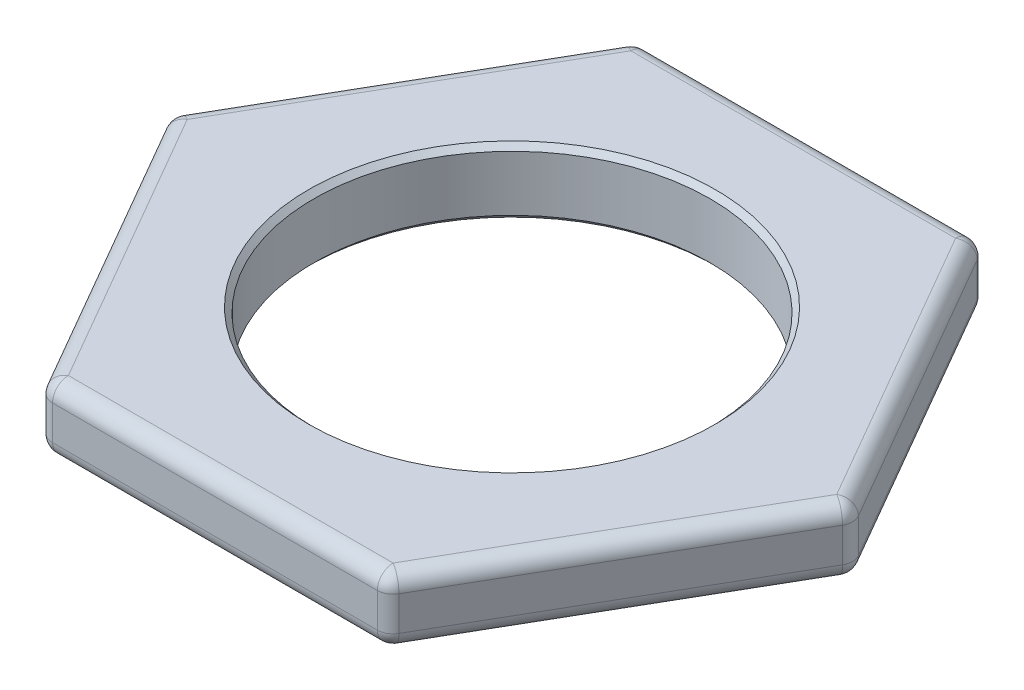
from build123d import *

# Parameters (mm, degrees)
SKETCH1_R           = 9.525
BOSS_EXTRUDE1_DEPTH = 3.175
CHAMFER1_SIZE       = 0.254
FILLET1_R           = 0.762


with BuildPart() as part:
    # Sketch1 → Boss-Extrude1 (new body)
    with BuildSketch(Plane(origin=(0, 0, 0), x_dir=(1, 0, 0), z_dir=(0, 1, 0))):
        Polygon((-8.248891971, -14.2875), (8.248891971, -14.2875), (16.497783942, 0), (8.248891971, 14.2875), (-8.248891971, 14.2875), (-16.497783942, 0), align=None)
        Circle(SKETCH1_R, mode=Mode.SUBTRACT)
    extrude(amount=BOSS_EXTRUDE1_DEPTH)

    # Chamfer1
    chamfer1_edges = [part.edges().sort_by_distance(p)[0] for p in [
        (-9.525, 0, 0),
        (-9.525, 3.175, 0),
    ]]
    chamfer(chamfer1_edges, length=CHAMFER1_SIZE)

    # Fillet1
    fillet1_edges = [part.edges().sort_by_distance(p)[0] for p in [
        (12.373337957, 3.175, 7.14375),
        (-16.497783942, 1.5875, 0),
        (-8.248891971, 1.5875, -14.2875),
        (8.248891971, 1.5875, -14.2875),
        (16.497783942, 1.5875, 0),
        (8.248891971, 1.5875, 14.2875),
        (-8.248891971, 1.5875, 14.2875),
        (12.373337957, 3.175, -7.14375),
        (0, 3.175, -14.2875),
        (-12.373337957, 3.175, -7.14375),
        (-12.373337957, 3.175, 7.14375),
        (-12.373337957, 0, -7.14375),
        (0, 0, -14.2875),
        (12.373337957, 0, -7.14375),
        (0, 3.175, 14.2875),
        (12.373337957, 0, 7.14375),
        (0, 0, 14.2875),
        (-12.373337957, 0, 7.14375),
    ]]
    fillet(fillet1_edges, radius=FILLET1_R)


solid = part.part
